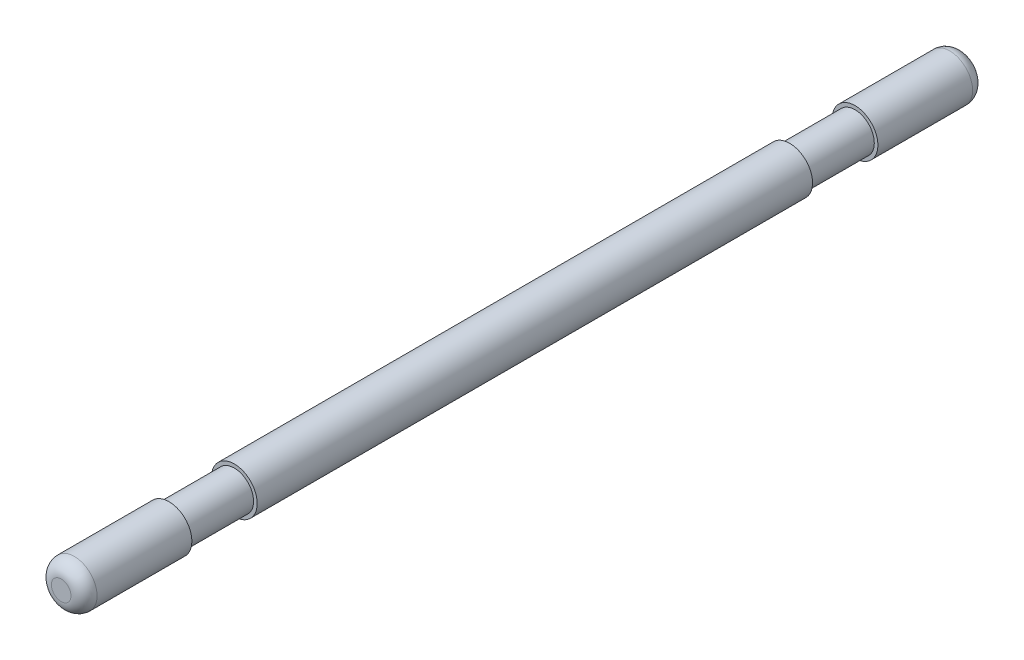
from build123d import *

# Parameters (mm, degrees)
SKETCH1_R            = 7
BOSS_EXTRUDE1_DEPTH  = 130
SKETCH9_R            = 7
SKETCH9_R_2          = 3.759161882
BOSS_EXTRUDE7_DEPTH  = 5
SKETCH10_R           = 7
BOSS_EXTRUDE8_DEPTH  = 3
FILLET6_R            = 4
SKETCH12_R           = 7
SKETCH12_R_2         = 2.9
BOSS_EXTRUDE9_DEPTH  = 5
SKETCH13_R           = 7
BOSS_EXTRUDE10_DEPTH = 3
FILLET7_R            = 4
SKETCH15_R           = 7
SKETCH15_R_2         = 5.9
CUT_EXTRUDE1_DEPTH   = 20
SKETCH16_R           = 7
SKETCH16_R_2         = 5.9
CUT_EXTRUDE2_DEPTH   = 20


with BuildPart() as part:
    # Sketch1 → Boss-Extrude1 (new body, symmetric)
    with BuildSketch(Plane.XY):
        Circle(SKETCH1_R)
    extrude(amount=BOSS_EXTRUDE1_DEPTH, both=True)

    # Sketch9 → Boss-Extrude7 (add)
    with BuildSketch(Plane(origin=(0, 0, -130), x_dir=(-1, 0, 0), z_dir=(0, 0, -1))):
        Circle(SKETCH9_R)
        Circle(SKETCH9_R_2, mode=Mode.SUBTRACT)
    extrude(amount=BOSS_EXTRUDE7_DEPTH)

    # Sketch10 → Boss-Extrude8 (add)
    with BuildSketch(Plane(origin=(0, 0, -135), x_dir=(-1, 0, 0), z_dir=(0, 0, -1))):
        Circle(SKETCH10_R)
    extrude(amount=BOSS_EXTRUDE8_DEPTH)

    # Fillet6
    fillet6_edges = [part.edges().sort_by_distance(p)[0] for p in [
        (7, 0, -138),
    ]]
    fillet(fillet6_edges, radius=FILLET6_R)

    # Sketch12 → Boss-Extrude9 (add)
    with BuildSketch(Plane.XY.offset(130)):
        Circle(SKETCH12_R)
        Circle(SKETCH12_R_2, mode=Mode.SUBTRACT)
    extrude(amount=BOSS_EXTRUDE9_DEPTH)

    # Sketch13 → Boss-Extrude10 (add)
    with BuildSketch(Plane.XY.offset(135)):
        Circle(SKETCH13_R)
    extrude(amount=BOSS_EXTRUDE10_DEPTH)

    # Fillet7
    fillet7_edges = [part.edges().sort_by_distance(p)[0] for p in [
        (-7, 0, 138),
    ]]
    fillet(fillet7_edges, radius=FILLET7_R)

    # Sketch15 → Cut-Extrude1 (cut)
    with BuildSketch(Plane.XY.offset(105)):
        Circle(SKETCH15_R)
        Circle(SKETCH15_R_2, mode=Mode.SUBTRACT)
    extrude(amount=-CUT_EXTRUDE1_DEPTH, mode=Mode.SUBTRACT)

    # Sketch16 → Cut-Extrude2 (cut)
    with BuildSketch(Plane.XY.offset(-105)):
        Circle(SKETCH16_R)
        Circle(SKETCH16_R_2, mode=Mode.SUBTRACT)
    extrude(amount=CUT_EXTRUDE2_DEPTH, mode=Mode.SUBTRACT)


solid = part.part
